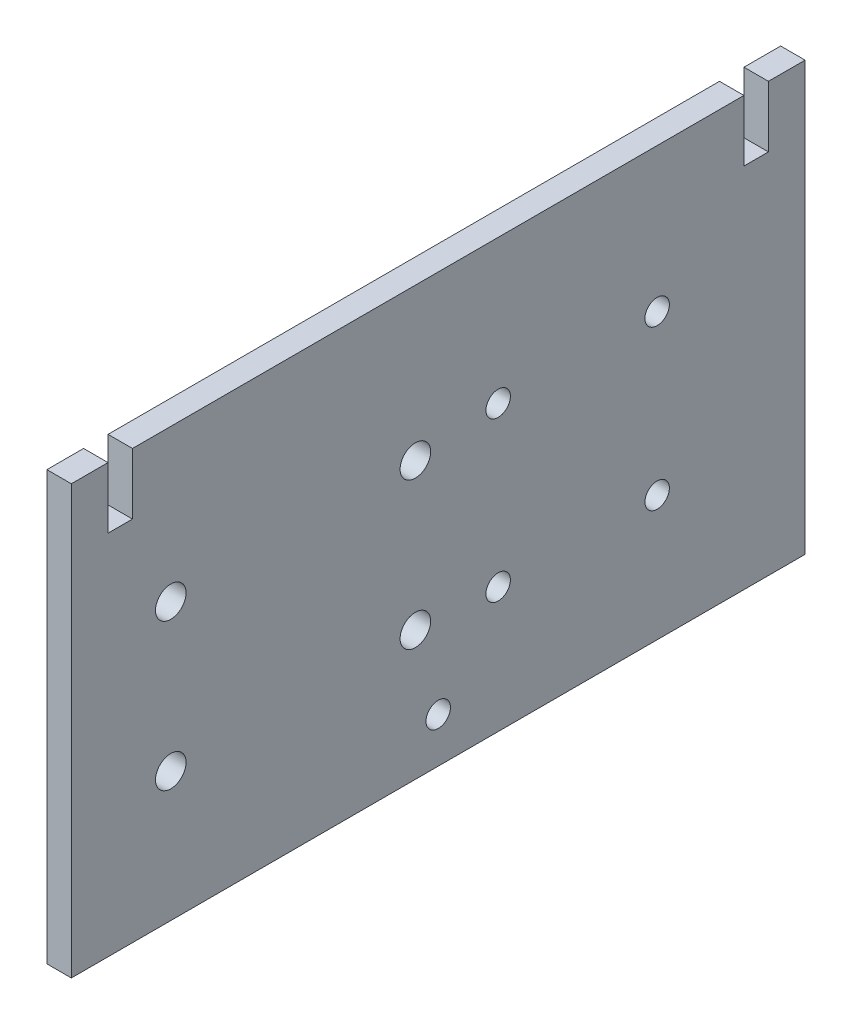
from build123d import *

# Parameters (mm, degrees)
SKETCH_1_W          = 120
SKETCH_1_H          = 70
EXTRUDE_1_DEPTH     = 4
SKETCH_2_R          = 2
SKETCH_2_W          = 4
SKETCH_2_H          = 10
CUT_EXTRUDE_1_DEPTH = 5
SKETCH_3_R          = 2.5
SKETCH_3_R_2        = 2
CUT_EXTRUDE_2_DEPTH = 5


with BuildPart() as part:
    # Эскиз1 → Бобышка-Вытянуть1 (new body)
    with BuildSketch(Plane(origin=(0, 0, 0), x_dir=(0, 0, -1), z_dir=(1, 0, 0))):
        Rectangle(SKETCH_1_W, SKETCH_1_H)
    extrude(amount=EXTRUDE_1_DEPTH)

    # Эскиз2 → Вырез-Вытянуть1 (cut, through all)
    with BuildSketch(Plane(origin=(4, 0, 0), x_dir=(0, 0, -1), z_dir=(1, 0, 0))):
        with Locations((0, -27.660492885)):
            Circle(SKETCH_2_R)
        with Locations((-52, 30)):
            Rectangle(SKETCH_2_W, SKETCH_2_H)
        with Locations((52, 30)):
            Rectangle(SKETCH_2_W, SKETCH_2_H)
    extrude(amount=-CUT_EXTRUDE_1_DEPTH, mode=Mode.SUBTRACT)

    # Эскиз3 → Вырез-Вытянуть2 (cut, through all)
    with BuildSketch(Plane(origin=(4, 0, 0), x_dir=(0, 0, -1), z_dir=(1, 0, 0))):
        with Locations((-43.737507579, 10.172241739)):
            Circle(SKETCH_3_R)
        with Locations((-43.737507579, -13.827758261)):
            Circle(SKETCH_3_R)
        with Locations((-3.737507579, -13.827758261)):
            Circle(SKETCH_3_R)
        with Locations((-3.737507579, 10.172241739)):
            Circle(SKETCH_3_R)
        with Locations((9.8030981, 11.493999532)):
            Circle(SKETCH_3_R_2)
        with Locations((35.8030981, 11.493999532)):
            Circle(SKETCH_3_R_2)
        with Locations((35.8030981, -14.506000468)):
            Circle(SKETCH_3_R_2)
        with Locations((9.8030981, -14.506000468)):
            Circle(SKETCH_3_R_2)
    extrude(amount=-CUT_EXTRUDE_2_DEPTH, mode=Mode.SUBTRACT)


solid = part.part
